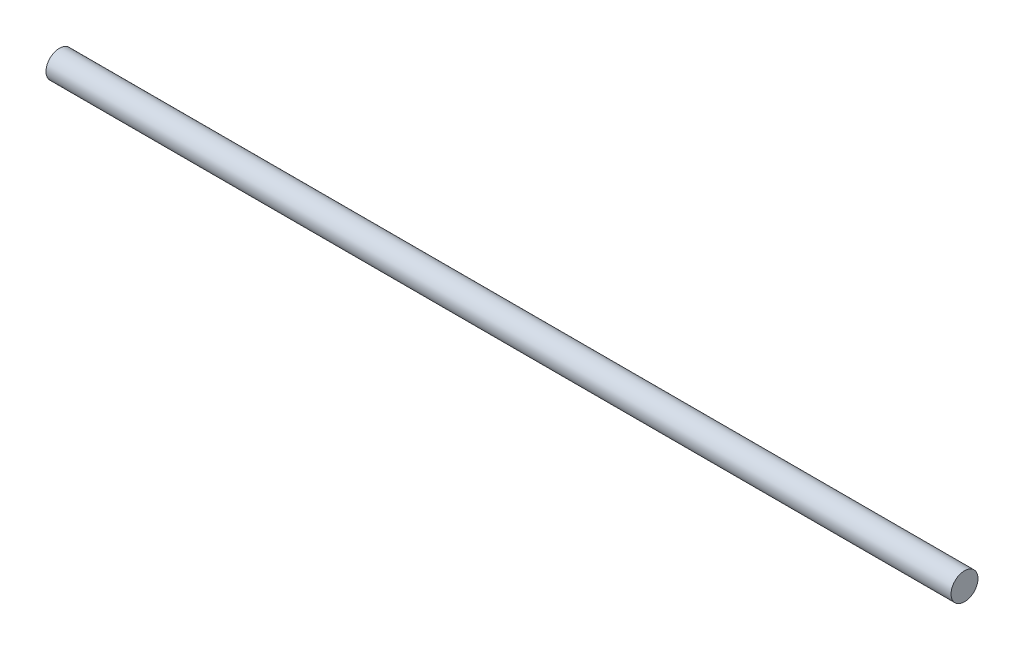
from build123d import *

# Parameters (mm, degrees)
SKETCH1_R           = 4.765
BOSS_EXTRUDE1_DEPTH = 320


with BuildPart() as part:
    # Sketch1 → Boss-Extrude1 (new body)
    with BuildSketch(Plane(origin=(0, 0, 0), x_dir=(0, 0, -1), z_dir=(1, 0, 0))):
        Circle(SKETCH1_R)
    extrude(amount=BOSS_EXTRUDE1_DEPTH)


solid = part.part
